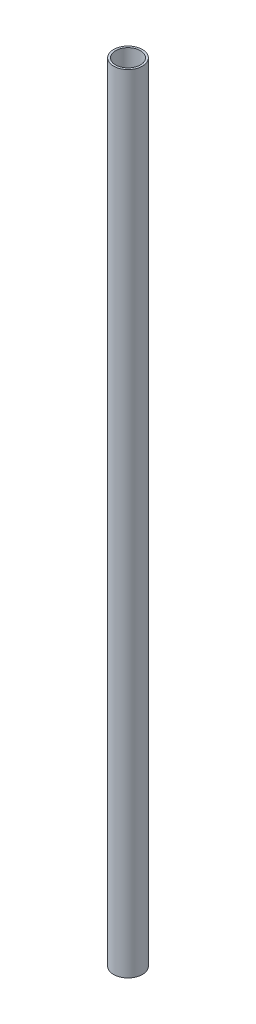
from build123d import *

# Parameters (mm, degrees)
SKETCH1_R           = 12.7
SKETCH1_R_2         = 10.922
BOSS_EXTRUDE2_DEPTH = 692.15


with BuildPart() as part:
    # Sketch1 → Boss-Extrude2 (new body)
    with BuildSketch(Plane(origin=(0, 0, 0), x_dir=(1, 0, 0), z_dir=(0, 1, 0))):
        Circle(SKETCH1_R)
        Circle(SKETCH1_R_2, mode=Mode.SUBTRACT)
    extrude(amount=BOSS_EXTRUDE2_DEPTH)


solid = part.part
